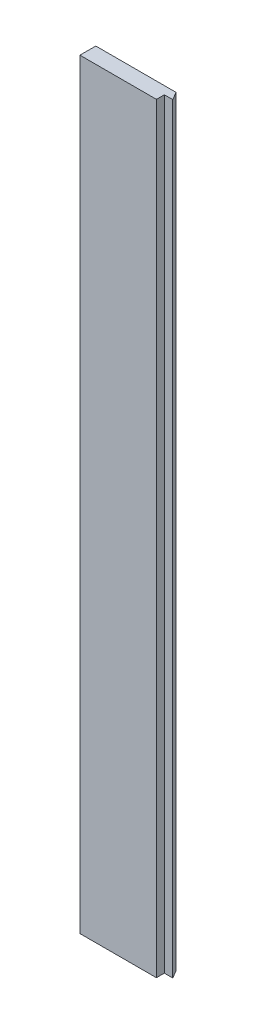
from build123d import *

# Parameters (mm, degrees)
SHAPE_DEPTH        = 1000
CUT_EXTRUDE8_REACH = 20
SKETCH10_W         = 5.196152423
SKETCH10_H         = 136.851692929
SKETCH10_W_2       = 91.107695154
SKETCH10_W_3       = 23.696152423
SKETCH10_H_2       = 863.148307071


with BuildPart() as part:
    # Sketch1 → Shape (new body)
    with BuildSketch(Plane(origin=(0, 0, 0), x_dir=(1, 0, 0), z_dir=(0, 1, 0))):
        Polygon((-41.5, 0), (-60, 0), (-60, -9), (50.5, -9), (50.5, 0), (60, 0), (54.803847577, 9), (-36.303847577, 9), align=None)
    extrude(amount=SHAPE_DEPTH)

    # Sketch10 → Cut-Extrude8 (cut, up to next)
    with BuildSketch(Plane(origin=(0, 0, -9), x_dir=(-1, 0, 0), z_dir=(0, 0, -1)), mode=Mode.PRIVATE) as cut_extrude8_sk1:
        with Locations((-57.401923789, 931.574153536)):
            Rectangle(SKETCH10_W, SKETCH10_H)
    cut_extrude8_tool1 = extrude(cut_extrude8_sk1.sketch, amount=-CUT_EXTRUDE8_REACH, mode=Mode.PRIVATE) & part.part
    add(cut_extrude8_tool1.solids().sort_by_distance((57.401924, 931.574154, -9))[0], mode=Mode.SUBTRACT)
    # Sketch10 → Cut-Extrude8 (cut, up to next)
    with BuildSketch(Plane(origin=(0, 0, -9), x_dir=(-1, 0, 0), z_dir=(0, 0, -1)), mode=Mode.PRIVATE) as cut_extrude8_sk2:
        with Locations((-9.25, 931.574153536)):
            Rectangle(SKETCH10_W_2, SKETCH10_H)
    cut_extrude8_tool2 = extrude(cut_extrude8_sk2.sketch, amount=-CUT_EXTRUDE8_REACH, mode=Mode.PRIVATE) & part.part
    add(cut_extrude8_tool2.solids().sort_by_distance((9.25, 931.574154, -9))[0], mode=Mode.SUBTRACT)
    # Sketch10 → Cut-Extrude8 (cut, up to next)
    with BuildSketch(Plane(origin=(0, 0, -9), x_dir=(-1, 0, 0), z_dir=(0, 0, -1)), mode=Mode.PRIVATE) as cut_extrude8_sk3:
        with Locations((48.151923788, 931.574153536)):
            Rectangle(SKETCH10_W_3, SKETCH10_H)
    cut_extrude8_tool3 = extrude(cut_extrude8_sk3.sketch, amount=-CUT_EXTRUDE8_REACH, mode=Mode.PRIVATE) & part.part
    add(cut_extrude8_tool3.solids().sort_by_distance((-48.151924, 931.574154, -9))[0], mode=Mode.SUBTRACT)
    # Sketch10 → Cut-Extrude8 (cut, up to next)
    with BuildSketch(Plane(origin=(0, 0, -9), x_dir=(-1, 0, 0), z_dir=(0, 0, -1)), mode=Mode.PRIVATE) as cut_extrude8_sk4:
        with Locations((48.151923788, 431.574153536)):
            Rectangle(SKETCH10_W_3, SKETCH10_H_2)
    cut_extrude8_tool4 = extrude(cut_extrude8_sk4.sketch, amount=-CUT_EXTRUDE8_REACH, mode=Mode.PRIVATE) & part.part
    add(cut_extrude8_tool4.solids().sort_by_distance((-48.151924, 431.574154, -9))[0], mode=Mode.SUBTRACT)


solid = part.part
